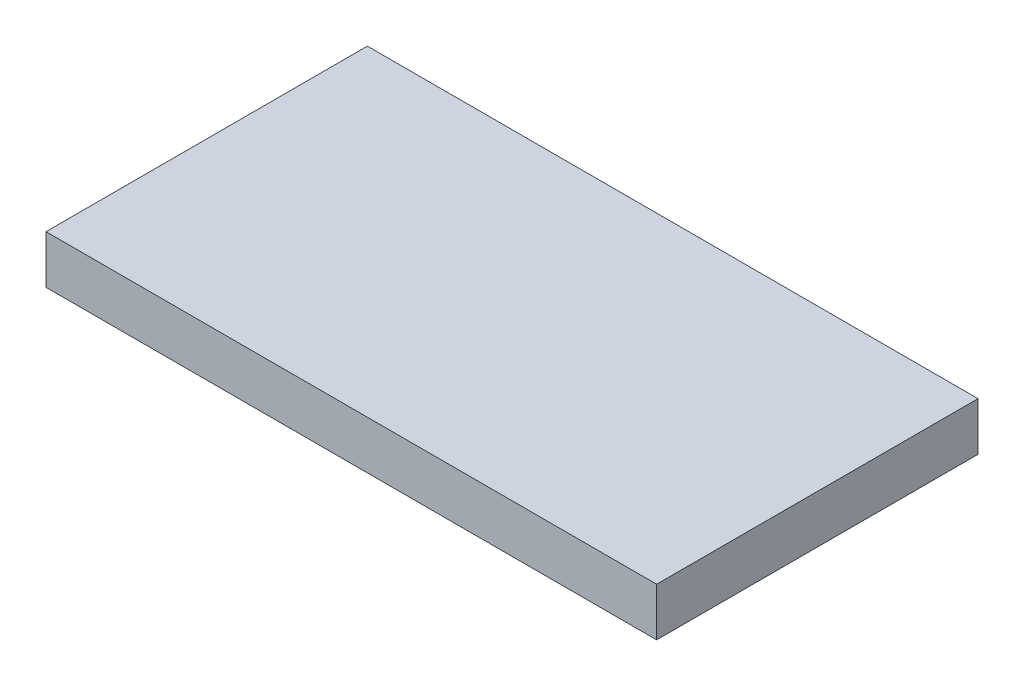
from build123d import *

# Parameters (mm, degrees)
SKETCH1_W           = 965.2
SKETCH1_H           = 508
BOSS_EXTRUDE1_DEPTH = 76.2
SKETCH1_5_R         = 25.4
CUT_EXTRUDE1_DEPTH  = 25.4


with BuildPart() as part:
    # Sketch1 → Boss-Extrude1 (new body)
    with BuildSketch(Plane(origin=(0, 0, 0), x_dir=(1, 0, 0), z_dir=(0, 1, 0))):
        with Locations((7.531475682, 2.445222165)):
            Rectangle(SKETCH1_W, SKETCH1_H)
    extrude(amount=BOSS_EXTRUDE1_DEPTH)

    # Sketch1_5 → Cut-Extrude1 (cut)
    with BuildSketch(Plane(origin=(0, 0, 0), x_dir=(1, 0, 0), z_dir=(0, 1, 0))):
        with Locations((-246.468524318, 154.845222165)):
            Circle(SKETCH1_5_R)
        with Locations((261.531475682, 154.845222165)):
            Circle(SKETCH1_5_R)
        with Locations((261.531475682, -149.954777835)):
            Circle(SKETCH1_5_R)
        with Locations((-246.468524318, -149.954777835)):
            Circle(SKETCH1_5_R)
    extrude(amount=CUT_EXTRUDE1_DEPTH, mode=Mode.SUBTRACT)


solid = part.part
